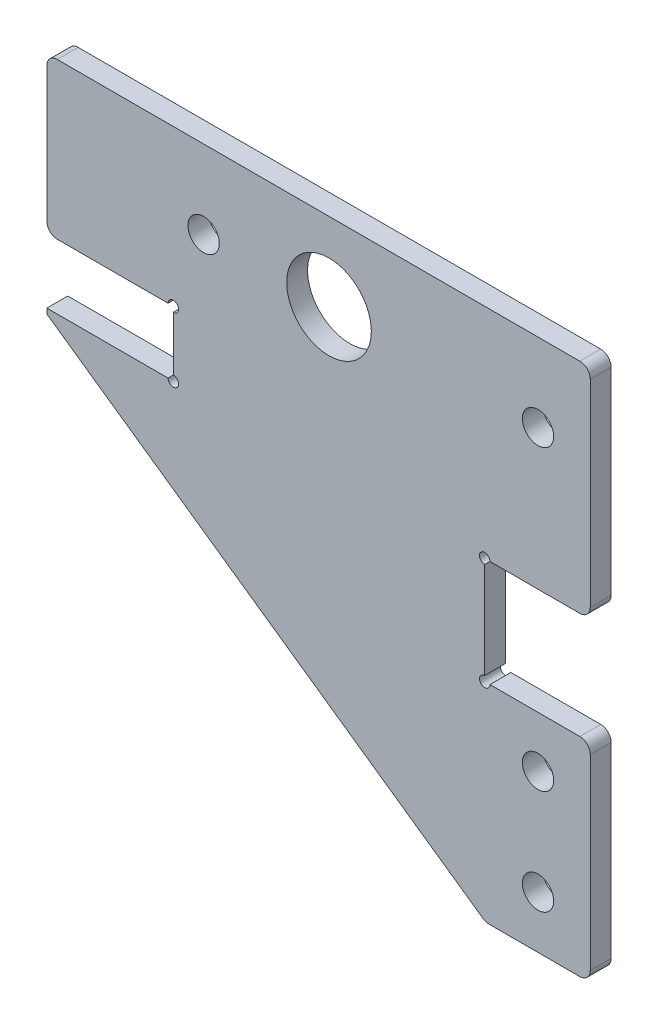
from build123d import *

# Parameters (mm, degrees)
SKETCH_1_R          = 1.5
SKETCH_1_R_2        = 4.05
EXTRUDE_1_DEPTH     = 2
SKETCH_2_R          = 0.5
CUT_EXTRUDE_1_DEPTH = 10
FILLET_1_R          = 1


with BuildPart() as part:
    # 草图1 → 凸台-拉伸1 (new body)
    with BuildSketch(Plane.XY):
        Polygon((-5, -43.5), (5, -43.5), (5, -23.6), (-5.1, -23.6), (-5.1, -13.4), (5, -13.4), (5, 7.5), (-47, 7.5), (-47, -7.4), (-34.9, -7.4), (-34.9, -13.6), (-47, -13.6), (-47, -14.091283395), align=None)
        with Locations((-32, 0)):
            Circle(SKETCH_1_R, mode=Mode.SUBTRACT)
        Circle(SKETCH_1_R, mode=Mode.SUBTRACT)
        with Locations((0, -38.5)):
            Circle(SKETCH_1_R, mode=Mode.SUBTRACT)
        with Locations((0, -28.5)):
            Circle(SKETCH_1_R, mode=Mode.SUBTRACT)
        with Locations((-20, 0)):
            Circle(SKETCH_1_R_2, mode=Mode.SUBTRACT)
    extrude(amount=EXTRUDE_1_DEPTH)

    # 草图2 → 切除-拉伸1 (cut)
    with BuildSketch(Plane.XY.offset(2)):
        with Locations((-34.9, -7.4)):
            Circle(SKETCH_2_R)
        with Locations((-34.9, -13.6)):
            Circle(SKETCH_2_R)
        with Locations((-5.1, -13.4)):
            Circle(SKETCH_2_R)
        with Locations((-5.1, -23.6)):
            Circle(SKETCH_2_R)
    extrude(amount=-CUT_EXTRUDE_1_DEPTH, mode=Mode.SUBTRACT)

    # 圆角1
    fillet_1_edges = [part.edges().sort_by_distance(p)[0] for p in [
        (-47, -7.4, 1),
        (-47, 7.5, 1),
        (5, 7.5, 1),
        (5, -13.4, 1),
        (5, -23.6, 1),
        (5, -43.5, 1),
        (-5, -43.5, 1),
    ]]
    fillet(fillet_1_edges, radius=FILLET_1_R)


solid = part.part
